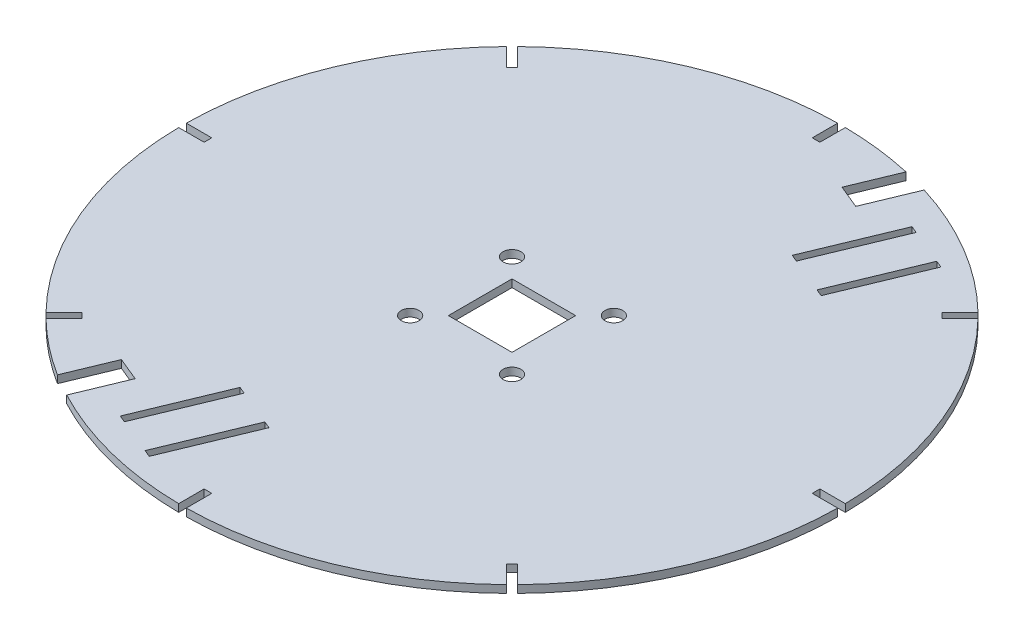
from build123d import *

# Parameters (mm, degrees)
SKETCH1_R               = 129.43
BOSS_EXTRUDE1_DEPTH     = 3
CUT_EXTRUDE2_START      = -3
CUT_EXTRUDE2_DEPTH      = 4
CIRPATTERN1_COUNT       = 8
SKETCH4_R               = 3.5
SKETCH4_W               = 25
SKETCH4_H               = 25
CUT_EXTRUDE3_DEPTH      = 3
CUT_EXTRUDE4_DEPTH      = 10
CUT_EXTRUDE5_DEPTH      = 1
CUT_EXTRUDE5_DEPTH_BACK = 3
CUT_EXTRUDE6_DEPTH      = 1
CUT_EXTRUDE6_DEPTH_BACK = 3


with BuildPart() as part:
    # Sketch1 → Boss-Extrude1 (new body)
    with BuildSketch(Plane(origin=(0, 0, 0), x_dir=(1, 0, 0), z_dir=(0, 1, 0))):
        Circle(SKETCH1_R)
    extrude(amount=BOSS_EXTRUDE1_DEPTH)

    # Sketch2 → Cut-Extrude2 (cut)
    with BuildSketch(Plane(origin=(0, 3, 0), x_dir=(1, 0, 0), z_dir=(0, 1, 0)).offset(CUT_EXTRUDE2_START)):
        Polygon((-1.5, 719.582197244), (-1.5, 129.421307751), (-1.5, 119.421307751), (1.5, 119.421307751), (1.5, 129.421307751), (1.5, 719.582197244), (1.5, 1899.903976231), (-1.5, 1899.903976231), align=None)
    cut_extrude2 = extrude(amount=CUT_EXTRUDE2_DEPTH, mode=Mode.SUBTRACT)

    # CirPattern1: Cut-Extrude2 ×8 about axis
    cirpattern1_axis = Axis((0, 0, 0), (0, -1, 0))
    for i in range(1, CIRPATTERN1_COUNT):
        add(cut_extrude2.rotate(cirpattern1_axis, i * 360 / CIRPATTERN1_COUNT), mode=Mode.SUBTRACT)

    # Sketch4 → Cut-Extrude3 (cut)
    with BuildSketch(Plane(origin=(0, 3, 0), x_dir=(1, 0, 0), z_dir=(0, 1, 0))):
        with Locations((20, 20)):
            Circle(SKETCH4_R)
        with Locations((20, -20)):
            Circle(SKETCH4_R)
        with Locations((-20, -20)):
            Circle(SKETCH4_R)
        with Locations((-20, 20)):
            Circle(SKETCH4_R)
        Rectangle(SKETCH4_W, SKETCH4_H)
    extrude(amount=-CUT_EXTRUDE3_DEPTH, mode=Mode.SUBTRACT)

    # Sketch5 → Cut-Extrude4 (cut)
    with BuildSketch(Plane(origin=(0, 3, 0), x_dir=(1, 0, 0), z_dir=(0, 1, 0))):
        Polygon((-42.767689854, -111.089714666), (-39.996051256, -112.237764963), (-26.219447691, -78.978101793), (-28.991086289, -77.830051496), align=None)
        Polygon((-26.137858269, -117.978016449), (-23.366219671, -119.126066746), (-9.589616106, -85.866403575), (-12.361254704, -84.718353278), align=None)
        Polygon((53.935833667, 67.497598822), (67.712437232, 100.757261992), (64.940798634, 101.905312289), (51.164195069, 68.645649119), align=None)
        Polygon((37.306002081, 74.385900604), (51.082605647, 107.645563775), (48.310967049, 108.793614072), (34.534363484, 75.533950901), align=None)
    extrude(amount=-CUT_EXTRUDE4_DEPTH, mode=Mode.SUBTRACT)

    # Sketch6 → Cut-Extrude5 (cut, two sides)
    with BuildSketch(Plane(origin=(0, 3, 0), x_dir=(1, 0, 0), z_dir=(0, 1, 0))) as cut_extrude5_sk:
        Polygon((264.658286272, 696.415643975), (28.490193223, 126.255430735), (21.127814063, 108.481075117), (30.356179145, 104.658561141), (38.225405343, 123.656553754), (274.393498392, 693.816766994), (592.742329798, 1886.329311701), (583.007117678, 1888.928188682), align=None)
    extrude(amount=CUT_EXTRUDE5_DEPTH, mode=Mode.SUBTRACT)
    extrude(cut_extrude5_sk.sketch, amount=-CUT_EXTRUDE5_DEPTH_BACK, mode=Mode.SUBTRACT)

    # Sketch8 → Cut-Extrude6 (cut, two sides)
    with BuildSketch(Plane(origin=(0, 3, 0), x_dir=(1, 0, 0), z_dir=(0, 1, 0))) as cut_extrude6_sk:
        Polygon((-310.659690478, -692.568815319), (-69.116017705, -109.430804605), (-61.752527909, -91.653767674), (-52.555273509, -95.463395183), (-60.423899034, -114.459937644), (-301.967571807, -697.597948358), (-934.16352501, -1790.255908717), (-942.855643681, -1785.226775678), align=None)
    extrude(amount=CUT_EXTRUDE6_DEPTH, mode=Mode.SUBTRACT)
    extrude(cut_extrude6_sk.sketch, amount=-CUT_EXTRUDE6_DEPTH_BACK, mode=Mode.SUBTRACT)


solid = part.part
